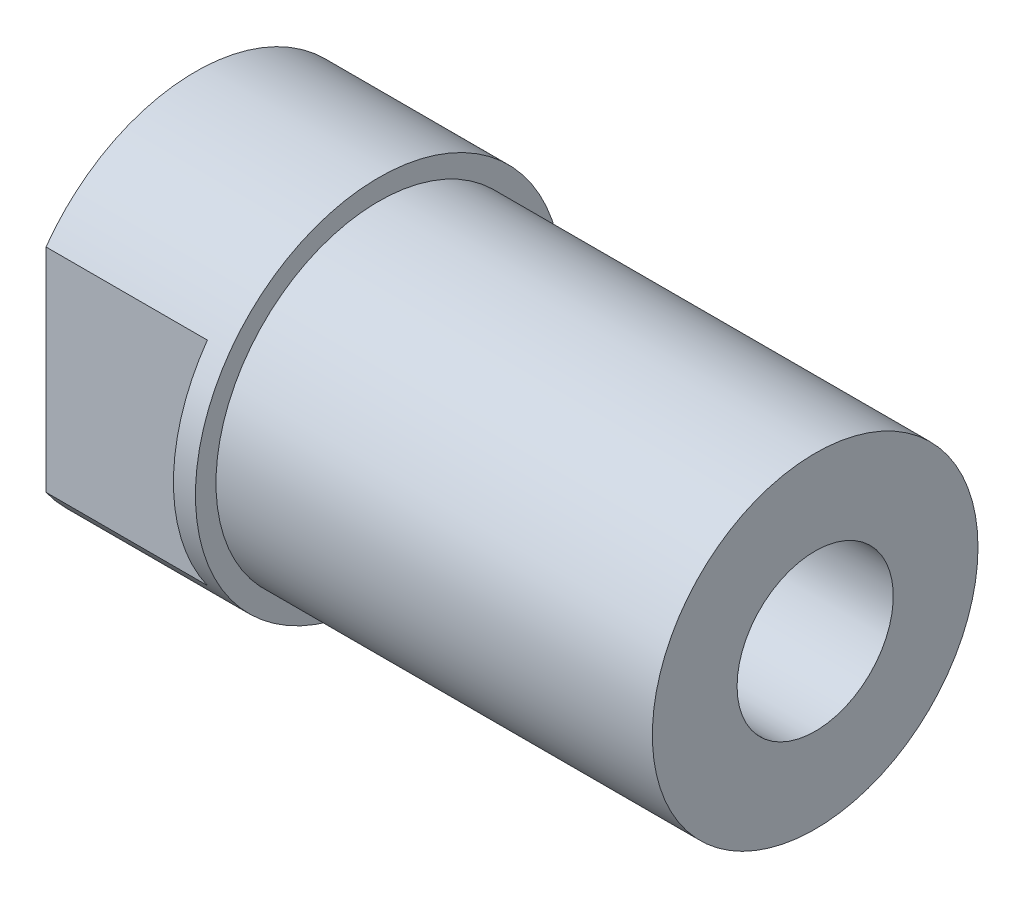
from build123d import *

# Parameters (mm, degrees)
SKETCH2_R               = 6.35
BOSS_EXTRUDE1_DEPTH     = 6.35
SKETCH3_R               = 5.6388
BOSS_EXTRUDE2_DEPTH     = 15.113
SKETCH4_W               = 5.588
SKETCH4_H               = 1.17475
CUT_EXTRUDE1_DEPTH      = 6.35
F_1_4_28_TAPPED_HOLE1_D = 5.4102


with BuildPart() as part:
    # Sketch2 → Boss-Extrude1 (new body)
    with BuildSketch(Plane(origin=(0, 0, 0), x_dir=(0, 0, -1), z_dir=(1, 0, 0))):
        Circle(SKETCH2_R)
    extrude(amount=-BOSS_EXTRUDE1_DEPTH)

    # Sketch3 → Boss-Extrude2 (add)
    with BuildSketch(Plane(origin=(0, 0, 0), x_dir=(0, 0, -1), z_dir=(1, 0, 0))):
        Circle(SKETCH3_R)
    extrude(amount=BOSS_EXTRUDE2_DEPTH)

    # Sketch4 → Cut-Extrude1 (cut, symmetric)
    with BuildSketch(Plane(origin=(0, 0, 0), x_dir=(1, 0, 0), z_dir=(0, 1, 0))):
        with Locations((-3.556, 5.762625)):
            Rectangle(SKETCH4_W, SKETCH4_H)
        with Locations((-3.556, -5.762625)):
            Rectangle(SKETCH4_W, SKETCH4_H)
    extrude(amount=CUT_EXTRUDE1_DEPTH, both=True, mode=Mode.SUBTRACT)

    # 1/4-28 Tapped Hole1 (through all)
    with Locations(Plane(origin=(-6.35, 0, 0), x_dir=(0, 0, -1), z_dir=(-1, 0, 0))):
        with Locations((0, 0)):
            Hole(F_1_4_28_TAPPED_HOLE1_D / 2)


solid = part.part
